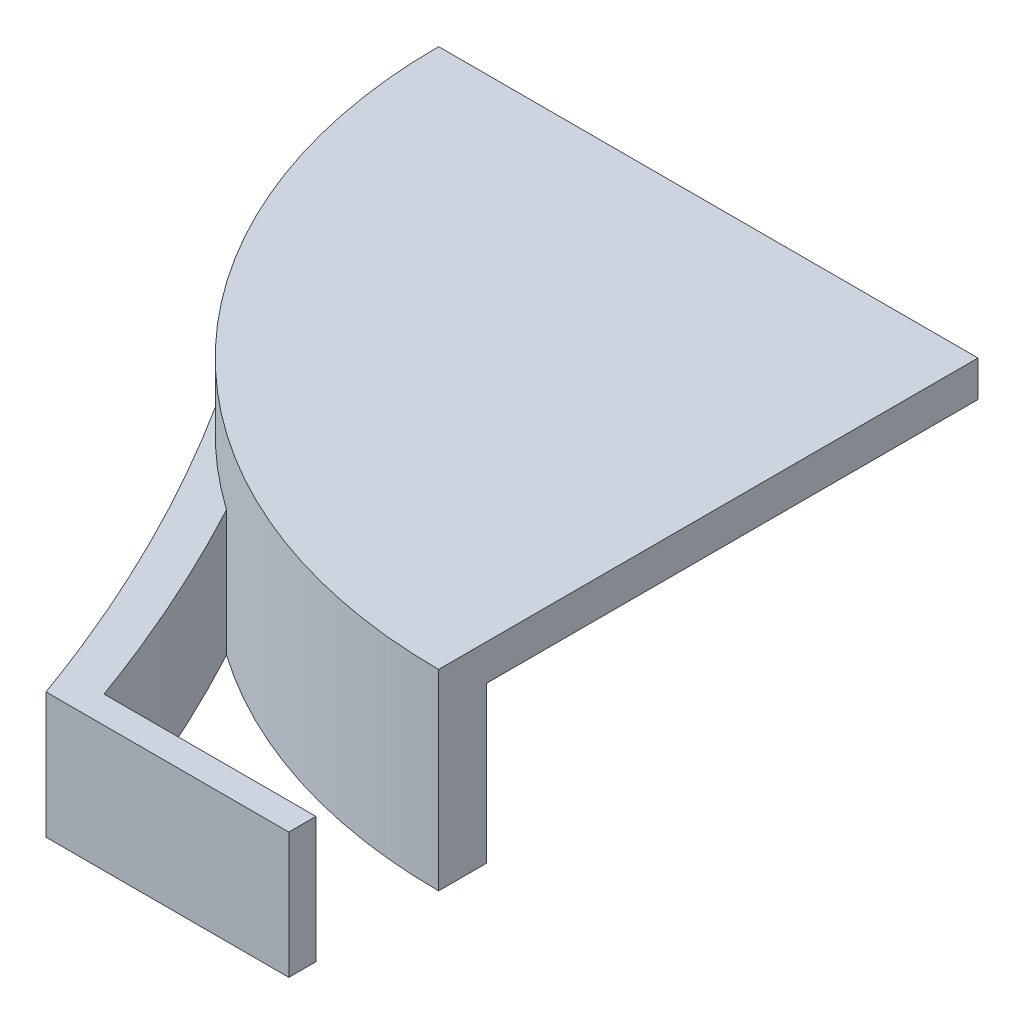
from build123d import *

# Parameters (mm, degrees)
SKETCH1_R           = 18
SKETCH1_R_2         = 16.4
BOSS_EXTRUDE1_DEPTH = 6.4
SKETCH2_R           = 16.4
BOSS_EXTRUDE2_DEPTH = 1.2
SKETCH3_W           = 28.944907734
SKETCH3_H           = 19.372936664
SKETCH3_W_2         = 25.830582219
CUT_EXTRUDE1_DEPTH  = 9.2
SKETCH4_W           = 21.729498485
SKETCH4_H           = 20.961841185
CUT_EXTRUDE2_DEPTH  = 9.2
BOSS_EXTRUDE3_DEPTH = 4.2


with BuildPart() as part:
    # Sketch1 → Boss-Extrude1 (new body)
    with BuildSketch(Plane(origin=(0, 0, 0), x_dir=(1, 0, 0), z_dir=(0, 1, 0))):
        Circle(SKETCH1_R)
        Circle(SKETCH1_R_2, mode=Mode.SUBTRACT)
    extrude(amount=BOSS_EXTRUDE1_DEPTH)

    # Sketch2 → Boss-Extrude2 (add)
    with BuildSketch(Plane(origin=(0, 6.4, 0), x_dir=(1, 0, 0), z_dir=(0, 1, 0))):
        Circle(SKETCH2_R)
    extrude(amount=-BOSS_EXTRUDE2_DEPTH)

    # Sketch3 → Cut-Extrude1 (cut)
    with BuildSketch(Plane(origin=(0, 6.4, 0), x_dir=(1, 0, 0), z_dir=(0, 1, 0))):
        with Locations((-14.472453867, 9.686468332)):
            Rectangle(SKETCH3_W, SKETCH3_H)
        with Locations((12.91529111, 9.686468332)):
            Rectangle(SKETCH3_W_2, SKETCH3_H)
    extrude(amount=-CUT_EXTRUDE1_DEPTH, mode=Mode.SUBTRACT)

    # Sketch4 → Cut-Extrude2 (cut)
    with BuildSketch(Plane(origin=(0, 6.4, 0), x_dir=(1, 0, 0), z_dir=(0, 1, 0))):
        with Locations((10.864749243, -10.480920593)):
            Rectangle(SKETCH4_W, SKETCH4_H)
    extrude(amount=-CUT_EXTRUDE2_DEPTH, mode=Mode.SUBTRACT)

    # Sketch7 → Boss-Extrude3 (add)
    with BuildSketch(Plane.XZ):
        with BuildLine():
            Line((-7.071454056, 22.094943573), (0, 22.094943573))
            Line((0, 22.094943573), (0, 23))
            Line((0, 23), (-8.102673091, 23))
            add(Edge.make_bspline(
                [(-13.608541935, 11.781663143), (-11.344094103, 15.333566486), (-9.508804488, 19.073012106), (-8.102673091, 23)],
                knots=[0.222401663, 0.222401663, 0.222401663, 0.222401663, 0.927765661, 0.927765661, 0.927765661, 0.927765661], degree=3))
            ThreePointArc((-13.608541935, 11.781663143), (-12.071131769, 13.352444638), (-10.353735644, 14.724135228))
            add(Edge.make_bspline(
                [(-10.353735644, 14.724135228), (-9.080392431, 17.10273932), (-7.986298568, 19.559675436), (-7.071454056, 22.094943573)],
                knots=[0.464158141, 0.464158141, 0.464158141, 0.464158141, 0.920020117, 0.920020117, 0.920020117, 0.920020117], degree=3))
        make_face()
    extrude(amount=-BOSS_EXTRUDE3_DEPTH)


solid = part.part
